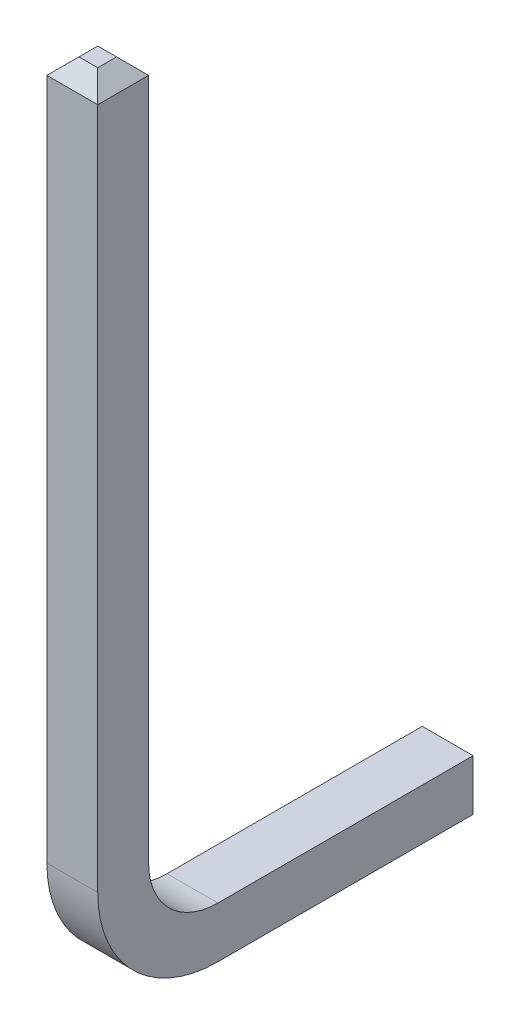
from build123d import *

# Parameters (mm, degrees)
BOSS_EXTRUDE1_DEPTH = 0.635
CHAMFER1_SIZE       = 0.2


with BuildPart() as part:
    # Sketch1 → Boss-Extrude1 (new body)
    with BuildSketch(Plane(origin=(0, 0, 0), x_dir=(0, 0, -1), z_dir=(1, 0, 0))):
        with BuildLine():
            Line((0.635, 1.5), (0.635, 10.2175))
            Line((0.635, 10.2175), (0, 10.2175))
            Line((0, 10.2175), (0, 1.5))
            ThreePointArc((0, 1.5), (0.439339828, 0.439339828), (1.5, 0))
            Line((1.5, 0), (4.887, 0))
            Line((4.887, 0), (4.887, 0.635))
            Line((4.887, 0.635), (1.5, 0.635))
            ThreePointArc((1.5, 0.635), (0.888352634, 0.888352634), (0.635, 1.5))
        make_face()
    extrude(amount=-BOSS_EXTRUDE1_DEPTH)

    # Chamfer1
    chamfer1_edges = [part.edges().sort_by_distance(p)[0] for p in [
        (0, 10.2175, -0.3175),
        (-0.3175, 10.2175, -0.635),
        (-0.3175, 10.2175, 0),
        (-0.635, 10.2175, -0.3175),
        (-0.3175, 0.635, -4.887),
        (-0.635, 0.3175, -4.887),
        (-0.3175, 0, -4.887),
        (0, 0.3175, -4.887),
    ]]
    chamfer(chamfer1_edges, length=CHAMFER1_SIZE)


solid = part.part
